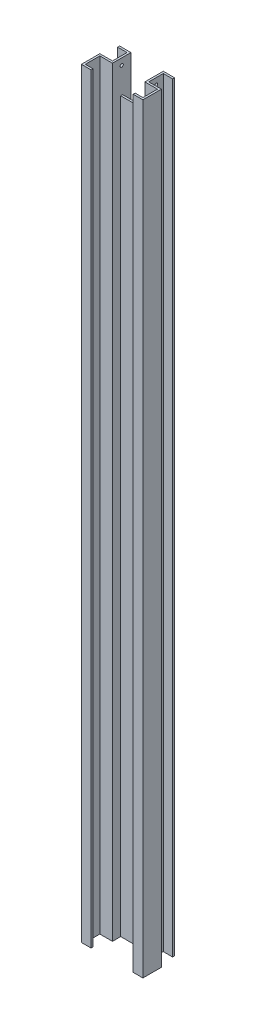
from build123d import *

# Parameters (mm, degrees)
SKETCH1_W                      = 45
SKETCH1_H                      = 2350
BOSS_EXTRUDE1_DEPTH            = 31.5
SKETCH2_W                      = 6
SKETCH2_H                      = 2350
BOSS_EXTRUDE2_DEPTH            = 145
SKETCH3_W                      = 45
SKETCH3_H                      = 2350
BOSS_EXTRUDE3_DEPTH            = 76.5
SKETCH4_W                      = 6
SKETCH4_H                      = 2350
BOSS_EXTRUDE4_DEPTH            = 51
SKETCH5_W                      = 6
SKETCH5_H                      = 2350
BOSS_EXTRUDE5_DEPTH            = 24
SKETCH6_W                      = 15
SKETCH6_H                      = 2350
CUT_EXTRUDE1_DEPTH             = 6
SKETCH7_W                      = 39
SKETCH7_H                      = 2350
CUT_EXTRUDE2_DEPTH             = 45
SKETCH8_W                      = 100
SKETCH8_H                      = 6
CUT_EXTRUDE3_DEPTH             = 100
SKETCH9_W                      = 45
SKETCH9_H                      = 2350
BOSS_EXTRUDE6_DEPTH            = 25.5
SKETCH10_W                     = 39
SKETCH10_H                     = 51
CUT_EXTRUDE4_DEPTH             = 2351
SKETCH11_W                     = 6
SKETCH11_H                     = 2350
BOSS_EXTRUDE7_DEPTH            = 29
SKETCH12_W                     = 45
SKETCH12_H                     = 2350
BOSS_EXTRUDE8_DEPTH            = 25.5
SKETCH13_W                     = 39
SKETCH13_H                     = 51
CUT_EXTRUDE5_DEPTH             = 2351
SKETCH14_W                     = 6
SKETCH14_H                     = 2350
BOSS_EXTRUDE9_DEPTH            = 29
F_10_0_10_DIAMETER_HOLE1_D     = 10
F_10_0_10_DIAMETER_HOLE1_DEPTH = 6
F_10_0_10_DIAMETER_HOLE2_D     = 10
F_10_0_10_DIAMETER_HOLE2_DEPTH = 45


with BuildPart() as part:
    # Sketch1 → Boss-Extrude1 (new body)
    with BuildSketch(Plane(origin=(0, 0, -76.5), x_dir=(-1, 0, 0), z_dir=(0, 0, -1))):
        with Locations((-72.5, 1175)):
            Rectangle(SKETCH1_W, SKETCH1_H)
    extrude(amount=-BOSS_EXTRUDE1_DEPTH)

    # Sketch2 → Boss-Extrude2 (add)
    with BuildSketch(Plane.ZY.offset(-50)):
        with Locations((-73.5, 1175)):
            Rectangle(SKETCH2_W, SKETCH2_H)
    extrude(amount=BOSS_EXTRUDE2_DEPTH)

    # Sketch3 → Boss-Extrude3 (add)
    with BuildSketch(Plane.XY.offset(-70.5)):
        with Locations((-72.5, 1175)):
            Rectangle(SKETCH3_W, SKETCH3_H)
    extrude(amount=BOSS_EXTRUDE3_DEPTH)

    # Sketch4 → Boss-Extrude4 (add)
    with BuildSketch(Plane.XY.offset(-45)):
        with Locations((92, 1175)):
            Rectangle(SKETCH4_W, SKETCH4_H)
    extrude(amount=BOSS_EXTRUDE4_DEPTH)

    # Sketch5 → Boss-Extrude5 (add)
    with BuildSketch(Plane.ZY.offset(-89)):
        with Locations((3, 1175)):
            Rectangle(SKETCH5_W, SKETCH5_H)
    extrude(amount=BOSS_EXTRUDE5_DEPTH)

    # Sketch6 → Cut-Extrude1 (cut)
    with BuildSketch(Plane.XY.offset(6)):
        with Locations((-57.5, 1175)):
            Rectangle(SKETCH6_W, SKETCH6_H)
    extrude(amount=-CUT_EXTRUDE1_DEPTH, mode=Mode.SUBTRACT)

    # Sketch7 → Cut-Extrude2 (cut)
    with BuildSketch(Plane.XY):
        with Locations((-69.5, 1175)):
            Rectangle(SKETCH7_W, SKETCH7_H)
    extrude(amount=-CUT_EXTRUDE2_DEPTH, mode=Mode.SUBTRACT)

    # Sketch8 → Cut-Extrude3 (cut)
    with BuildSketch(Plane(origin=(0, 2350, 0), x_dir=(-1, 0, 0), z_dir=(0, 1, 0))):
        with Locations((0, -73.5)):
            Rectangle(SKETCH8_W, SKETCH8_H)
    extrude(amount=-CUT_EXTRUDE3_DEPTH, mode=Mode.SUBTRACT)

    # Sketch9 → Boss-Extrude6 (add)
    with BuildSketch(Plane(origin=(0, 0, -76.5), x_dir=(-1, 0, 0), z_dir=(0, 0, -1))):
        with Locations((-72.5, 1175)):
            Rectangle(SKETCH9_W, SKETCH9_H)
    extrude(amount=BOSS_EXTRUDE6_DEPTH)

    # Sketch10 → Cut-Extrude4 (cut, through all)
    with BuildSketch(Plane.XZ):
        with Locations((75.5, -76.5)):
            Rectangle(SKETCH10_W, SKETCH10_H)
    extrude(amount=-CUT_EXTRUDE4_DEPTH, mode=Mode.SUBTRACT)

    # Sketch11 → Boss-Extrude7 (add)
    with BuildSketch(Plane(origin=(56, 0, 0), x_dir=(0, 0, -1), z_dir=(1, 0, 0))):
        with Locations((99, 1175)):
            Rectangle(SKETCH11_W, SKETCH11_H)
    extrude(amount=BOSS_EXTRUDE7_DEPTH)

    # Sketch12 → Boss-Extrude8 (add)
    with BuildSketch(Plane(origin=(0, 0, -76.5), x_dir=(-1, 0, 0), z_dir=(0, 0, -1))):
        with Locations((72.5, 1175)):
            Rectangle(SKETCH12_W, SKETCH12_H)
    extrude(amount=BOSS_EXTRUDE8_DEPTH)

    # Sketch13 → Cut-Extrude5 (cut, through all)
    with BuildSketch(Plane(origin=(0, 2350, 0), x_dir=(-1, 0, 0), z_dir=(0, 1, 0))):
        with Locations((75.5, -76.5)):
            Rectangle(SKETCH13_W, SKETCH13_H)
    extrude(amount=-CUT_EXTRUDE5_DEPTH, mode=Mode.SUBTRACT)

    # Sketch14 → Boss-Extrude9 (add)
    with BuildSketch(Plane.ZY.offset(56)):
        with Locations((-99, 1175)):
            Rectangle(SKETCH14_W, SKETCH14_H)
    extrude(amount=BOSS_EXTRUDE9_DEPTH)

    # Ø10.0 (10) Diameter Hole1
    with Locations(Plane.ZY.offset(56)):
        with Locations((-73.5, 2330)):
            Hole(F_10_0_10_DIAMETER_HOLE1_D / 2, depth=F_10_0_10_DIAMETER_HOLE1_DEPTH)

    # Ø10.0 (10) Diameter Hole2
    with Locations(Plane.ZY.offset(-50)):
        with Locations((-73.5, 2330)):
            Hole(F_10_0_10_DIAMETER_HOLE2_D / 2, depth=F_10_0_10_DIAMETER_HOLE2_DEPTH)


solid = part.part
